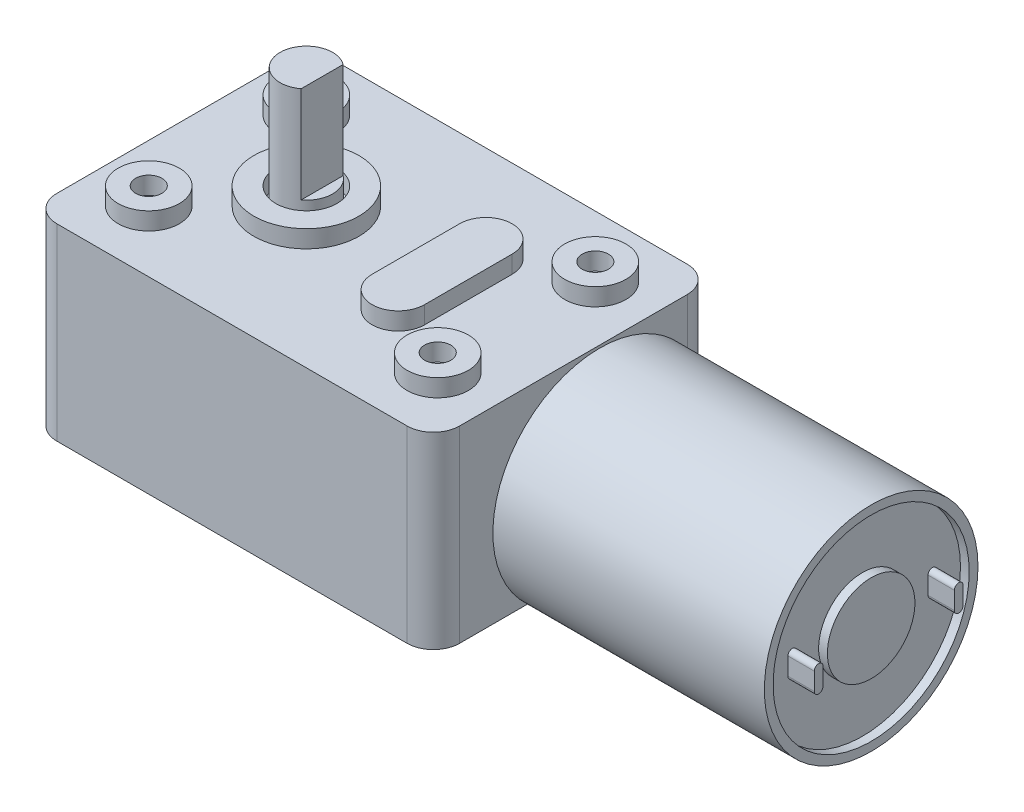
from build123d import *

# Parameters (mm, degrees)
SKETCH1_W           = 46
SKETCH1_H           = 32
BOSS_EXTRUDE1_DEPTH = 21.5
FILLET1_R           = 3
SKETCH2_R           = 3.5
SKETCH2_R_2         = 1.5
SKETCH2_R_3         = 6
BOSS_EXTRUDE2_DEPTH = 2
SKETCH3_R           = 3
BOSS_EXTRUDE3_DEPTH = 13.7
CUT_EXTRUDE1_DEPTH  = 11
SKETCH6_R           = 12.2
BOSS_EXTRUDE5_DEPTH = 31
SKETCH7_R           = 11.2
SKETCH7_R_2         = 5
CUT_EXTRUDE2_DEPTH  = 1
BOSS_EXTRUDE6_DEPTH = 3
CIRPATTERN1_COUNT   = 2


with BuildPart() as part:
    # Sketch1 → Boss-Extrude1 (new body)
    with BuildSketch(Plane(origin=(0, 0, 0), x_dir=(1, 0, 0), z_dir=(0, 1, 0))):
        Rectangle(SKETCH1_W, SKETCH1_H)
    extrude(amount=BOSS_EXTRUDE1_DEPTH)

    # Fillet1
    fillet1_edges = [part.edges().sort_by_distance(p)[0] for p in [
        (23, 10.75, 16),
        (-23, 10.75, 16),
        (-23, 10.75, -16),
        (23, 10.75, -16),
    ]]
    fillet(fillet1_edges, radius=FILLET1_R)

    # Sketch2 → Boss-Extrude2 (add)
    with BuildSketch(Plane(origin=(0, 21.5, 0), x_dir=(1, 0, 0), z_dir=(0, 1, 0))):
        with Locations((-16.5, 9)):
            Circle(SKETCH2_R)
        with Locations((-16.5, 9)):
            Circle(SKETCH2_R_2, mode=Mode.SUBTRACT)
        with Locations((16.5, 9)):
            Circle(SKETCH2_R)
        with Locations((16.5, 9)):
            Circle(SKETCH2_R_2, mode=Mode.SUBTRACT)
        with Locations((16.5, -9)):
            Circle(SKETCH2_R)
        with Locations((16.5, -9)):
            Circle(SKETCH2_R_2, mode=Mode.SUBTRACT)
        with Locations((-16.5, -9)):
            Circle(SKETCH2_R)
        with Locations((-16.5, -9)):
            Circle(SKETCH2_R_2, mode=Mode.SUBTRACT)
        with Locations((-7.5, 0)):
            Circle(SKETCH2_R_3)
        with Locations((-7.5, 0)):
            Circle(SKETCH2_R, mode=Mode.SUBTRACT)
        with BuildLine():
            Line((11, 5), (11, -5))
            ThreePointArc((11, -5), (8, -8), (5, -5))
            Line((5, -5), (5, 5))
            ThreePointArc((5, 5), (8, 8), (11, 5))
        make_face()
    extrude(amount=BOSS_EXTRUDE2_DEPTH)

    # Sketch3 → Boss-Extrude3 (add)
    with BuildSketch(Plane(origin=(0, 21.5, 0), x_dir=(1, 0, 0), z_dir=(0, 1, 0))):
        with Locations((-7.5, 0)):
            Circle(SKETCH3_R)
    extrude(amount=BOSS_EXTRUDE3_DEPTH)

    # Sketch4 → Cut-Extrude1 (cut)
    with BuildSketch(Plane(origin=(0, 35.2, 0), x_dir=(1, 0, 0), z_dir=(0, 1, 0))):
        Polygon((-5.7, 80.583575735), (-5.7, 2.4), (-5.7, -2.4), (-5.7, -80.583575735), (150.66715147, -80.583575735), (150.66715147, 80.583575735), align=None)
    extrude(amount=-CUT_EXTRUDE1_DEPTH, mode=Mode.SUBTRACT)

    # Sketch6 → Boss-Extrude5 (add)
    with BuildSketch(Plane(origin=(23, 0, 0), x_dir=(0, 0, -1), z_dir=(1, 0, 0))):
        with Locations((3, 9)):
            Circle(SKETCH6_R)
    extrude(amount=BOSS_EXTRUDE5_DEPTH)

    # Sketch7 → Cut-Extrude2 (cut)
    with BuildSketch(Plane(origin=(54, 0, 0), x_dir=(0, 0, -1), z_dir=(1, 0, 0))):
        with Locations((3, 9)):
            Circle(SKETCH7_R)
        with Locations((3, 9)):
            Circle(SKETCH7_R_2, mode=Mode.SUBTRACT)
    extrude(amount=-CUT_EXTRUDE2_DEPTH, mode=Mode.SUBTRACT)

    # Sketch8 → Boss-Extrude6 (add)
    with BuildSketch(Plane(origin=(53, 0, 0), x_dir=(0, 0, -1), z_dir=(1, 0, 0))):
        with BuildLine():
            Line((-5.5, 8), (-5.5, 10))
            ThreePointArc((-5.5, 10), (-5, 10.5), (-4.5, 10))
            Line((-4.5, 10), (-4.5, 8))
            ThreePointArc((-4.5, 8), (-5, 7.5), (-5.5, 8))
        make_face()
    boss_extrude6 = extrude(amount=BOSS_EXTRUDE6_DEPTH)

    # CirPattern1: Boss-Extrude6 ×2 about axis
    cirpattern1_axis = Axis((0, 9, -3), (1, 0, 0))
    for i in range(1, CIRPATTERN1_COUNT):
        add(boss_extrude6.rotate(cirpattern1_axis, i * 360 / CIRPATTERN1_COUNT))


solid = part.part
